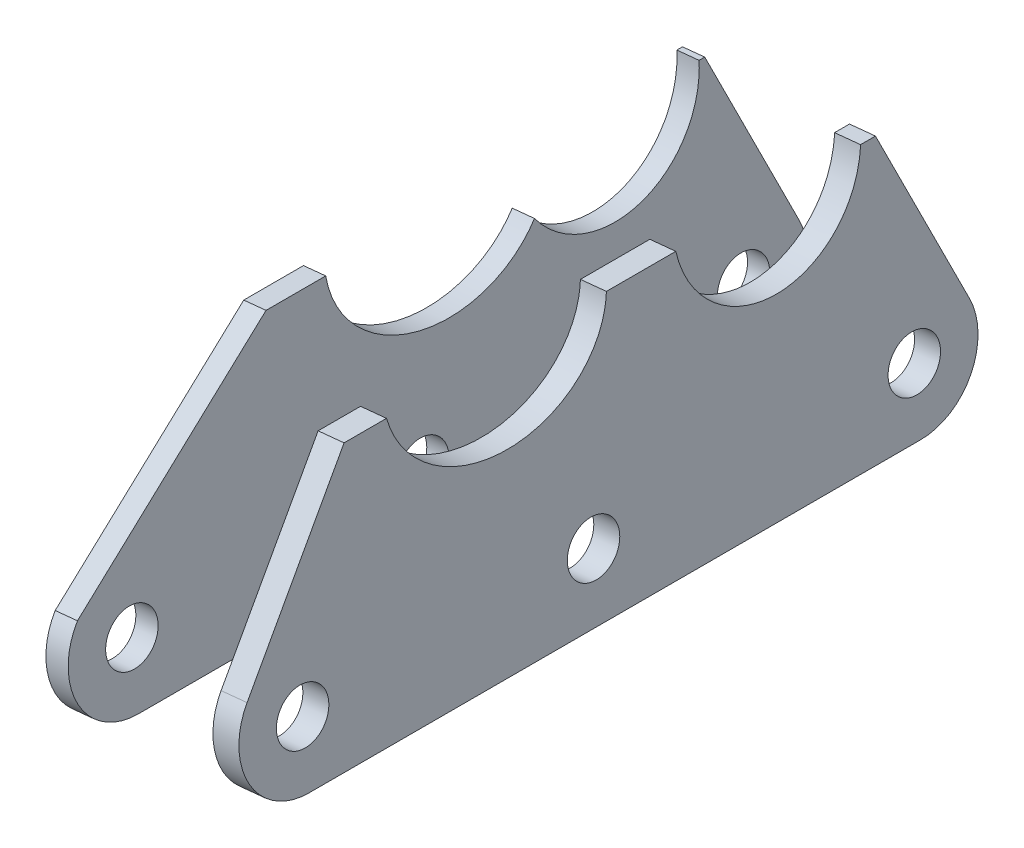
from build123d import *

# Parameters (mm, degrees)
SZKIC1_R                    = 3.5
DODANIE_WYCI_GNI_CIE1_DEPTH = 3.5
SZKIC2_R                    = 3.5
DODANIE_WYCI_GNI_CIE2_DEPTH = 3


with BuildPart() as part:
    # Szkic1 → Dodanie-wyciągnięcie1 (new body)
    with BuildSketch(Plane(origin=(1510.26539917, 150.162347119, 0), x_dir=(0, 0, 1), z_dir=(-0.995093407, -0.098939936, 0))):
        with BuildLine():
            Line((176, -389.244285112), (94, -389.244285112))
            ThreePointArc((94, -389.244285112), (86.863716206, -385.362017631), (86.246247121, -377.261568315))
            Line((86.246247121, -377.261568315), (96.584812208, -354.244285112))
            Line((96.584812208, -354.244285112), (98.584812208, -354.244285112))
            add(Edge.make_bspline(
                [(123.351051733, -354.244285112), (121.451794076, -366.991661985), (109.953835715, -368.077613983), (102.808126789, -361.943543508), (100.700327503, -360.134151396), (99.055830817, -357.52813016), (98.584812208, -354.244285112)],
                knots=[0.177741768, 0.177741768, 0.177741768, 0.177741768, 0.5, 0.5, 0.5, 0.636368468, 0.636368468, 0.636368468, 0.636368468], degree=3, weights=[0.541770017, 0.417579029, 0.570322357, 1, 0.818175377, 0.685941044, 0.603297001]))
            Line((123.351051733, -354.244285112), (132.653019729, -354.244285112))
            add(Edge.make_bspline(
                [(162.132083494, -354.244285112), (157.83407929, -374.622201078), (135.082547526, -371.957513924), (132.653019729, -354.244285112)],
                knots=[0.555739934, 0.555739934, 0.555739934, 0.555739934, 0.989987358, 0.989987358, 0.989987358, 0.989987358], degree=3, weights=[0.801895785, 0.351992143, 0.404944032, 0.960751454]))
            Line((162.132083494, -354.244285112), (167.821084242, -354.244285112))
            Line((167.821084242, -354.244285112), (182.962792376, -375.868885403))
            ThreePointArc((182.962792376, -375.868885403), (183.539592082, -384.669148324), (176, -389.244285112))
        make_face()
        with Locations((176, -380.744285112)):
            Circle(SZKIC1_R, mode=Mode.SUBTRACT)
        with Locations((137, -380.744285112)):
            Circle(SZKIC1_R, mode=Mode.SUBTRACT)
        with Locations((94, -380.744285112)):
            Circle(SZKIC1_R, mode=Mode.SUBTRACT)
    extrude(amount=DODANIE_WYCI_GNI_CIE1_DEPTH)


with BuildPart() as body_2:
    # Szkic2 → Dodanie-wyciągnięcie2 (new body)
    with BuildSketch(Plane(origin=(1487.378250803, 147.886728596, 0), x_dir=(0, 0, 1), z_dir=(-0.995093407, -0.098939936, 0))):
        with BuildLine():
            Line((94, -389.244285112), (176, -389.244285112))
            ThreePointArc((176, -389.244285112), (183.605532693, -384.539791989), (182.792200387, -375.633902161))
            Line((182.792200387, -375.633902161), (155.396482628, -354.244285112))
            Line((155.396482628, -354.244285112), (147.392323291, -354.244285112))
            add(Edge.make_bspline(
                [(147.392323291, -354.244285112), (146.155727883, -368.865974762), (129.40362382, -372.625709898), (120.0699746, -360.937702969)],
                knots=[0.514263128, 0.514263128, 0.514263128, 0.514263128, 1, 1, 1, 1], degree=3, weights=[0.960864578, 0.529651942, 0.542697083, 1]))
            add(Edge.make_bspline(
                [(120.0699746, -360.937702969), (114.863351071, -368.326546813), (106.77470385, -367.625007076), (101.683038198, -363.254183094), (99.274683189, -361.186785793), (97.48553021, -358.103092297), (97.341630267, -354.244285112)],
                knots=[0.238017488, 0.238017488, 0.238017488, 0.238017488, 0.5, 0.5, 0.5, 0.651875895, 0.651875895, 0.651875895, 0.651875895], degree=3, weights=[0.501148645, 0.484406199, 0.650689984, 1, 0.797498807, 0.656507714, 0.57702672]))
            Line((97.341630267, -354.244285112), (96.584812208, -354.244285112))
            Line((96.584812208, -354.244285112), (86.246247121, -377.261568315))
            ThreePointArc((86.246247121, -377.261568315), (86.863716206, -385.362017631), (94, -389.244285112))
        make_face()
        with Locations((94, -380.744285112)):
            Circle(SZKIC2_R, mode=Mode.SUBTRACT)
        with Locations((137, -380.744285112)):
            Circle(SZKIC2_R, mode=Mode.SUBTRACT)
        with Locations((176, -380.744285112)):
            Circle(SZKIC2_R, mode=Mode.SUBTRACT)
    extrude(amount=DODANIE_WYCI_GNI_CIE2_DEPTH)


solid = Compound([part.part, body_2.part])
